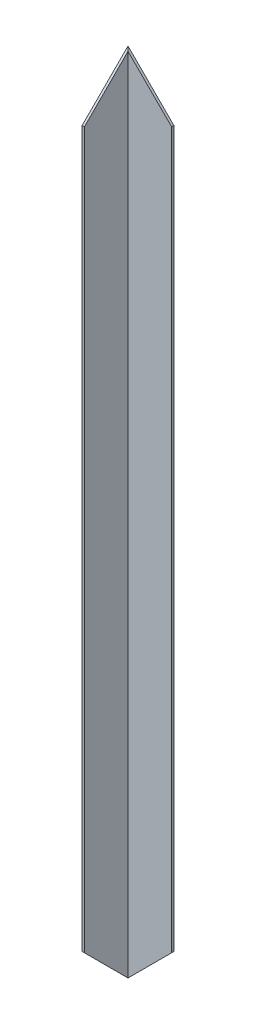
from build123d import *

# Parameters (mm, degrees)
BOSS_EXTRU_1_DEPTH      = 704
ENL_V_MAT_EXTRU_1_DEPTH = 590
ENL_V_MAT_EXTRU_2_DEPTH = 590
ENL_V_MAT_EXTRU_3_DEPTH = 41
ENL_V_MAT_EXTRU_4_DEPTH = 41


with BuildPart() as part:
    # Esquisse1 → Boss.-Extru.1 (new body)
    with BuildSketch(Plane(origin=(0, 0, 0), x_dir=(1, 0, 0), z_dir=(0, 1, 0))):
        Polygon((-20, 20.113636364), (20, 20.113636364), (20, 18.113636364), (-18, 18.113636364), (-18, -19.886363636), (-20, -19.886363636), align=None)
    extrude(amount=BOSS_EXTRU_1_DEPTH)

    # Esquisse2 → Enlèv. mat.-Extru.1 (cut)
    with BuildSketch(Plane(origin=(0, 0, -20.113636364), x_dir=(-1, 0, 0), z_dir=(0, 0, -1))):
        Polygon((20, 0), (-20, 40), (-20, 0), align=None)
    extrude(amount=-ENL_V_MAT_EXTRU_1_DEPTH, mode=Mode.SUBTRACT)

    # Esquisse3 → Enlèv. mat.-Extru.2 (cut)
    with BuildSketch(Plane.ZY.offset(20)):
        Polygon((-20.113636364, 0), (19.886363636, 40), (19.886363636, 0), align=None)
    extrude(amount=-ENL_V_MAT_EXTRU_2_DEPTH, mode=Mode.SUBTRACT)

    # Esquisse4 → Enlèv. mat.-Extru.3 (cut, through all)
    with BuildSketch(Plane.ZY.offset(20)):
        Polygon((-20.113636364, 704), (19.886363636, 664), (19.886363636, 704), align=None)
    extrude(amount=-ENL_V_MAT_EXTRU_3_DEPTH, mode=Mode.SUBTRACT)

    # Esquisse5 → Enlèv. mat.-Extru.4 (cut, through all)
    with BuildSketch(Plane(origin=(0, 0, -20.113636364), x_dir=(-1, 0, 0), z_dir=(0, 0, -1))):
        Polygon((20, 704), (-20, 664), (-20, 704), align=None)
    extrude(amount=-ENL_V_MAT_EXTRU_4_DEPTH, mode=Mode.SUBTRACT)


solid = part.part
